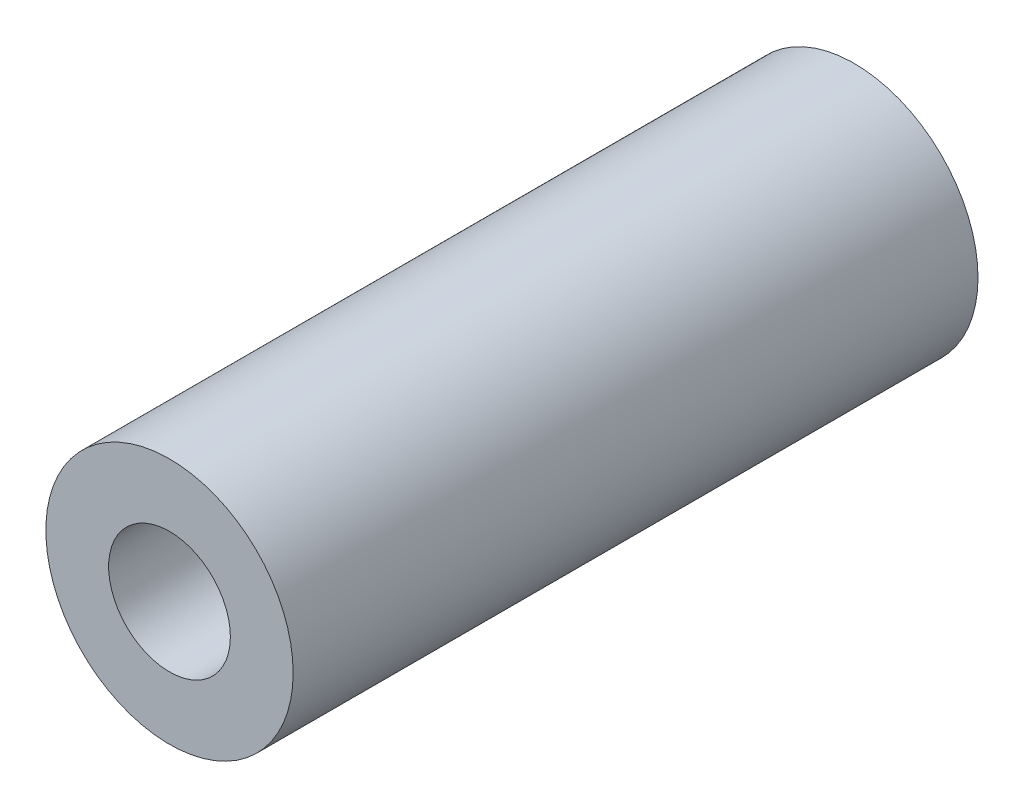
from build123d import *

# Parameters (mm, degrees)
ESBO_O1_R                = 3.25
ESBO_O1_R_2              = 1.6
RESSALTO_EXTRUS_O1_DEPTH = 18


with BuildPart() as part:
    # Esboço1 → Ressalto-extrusão1 (new body)
    with BuildSketch(Plane.XY):
        Circle(ESBO_O1_R)
        Circle(ESBO_O1_R_2, mode=Mode.SUBTRACT)
    extrude(amount=RESSALTO_EXTRUS_O1_DEPTH)


solid = part.part
